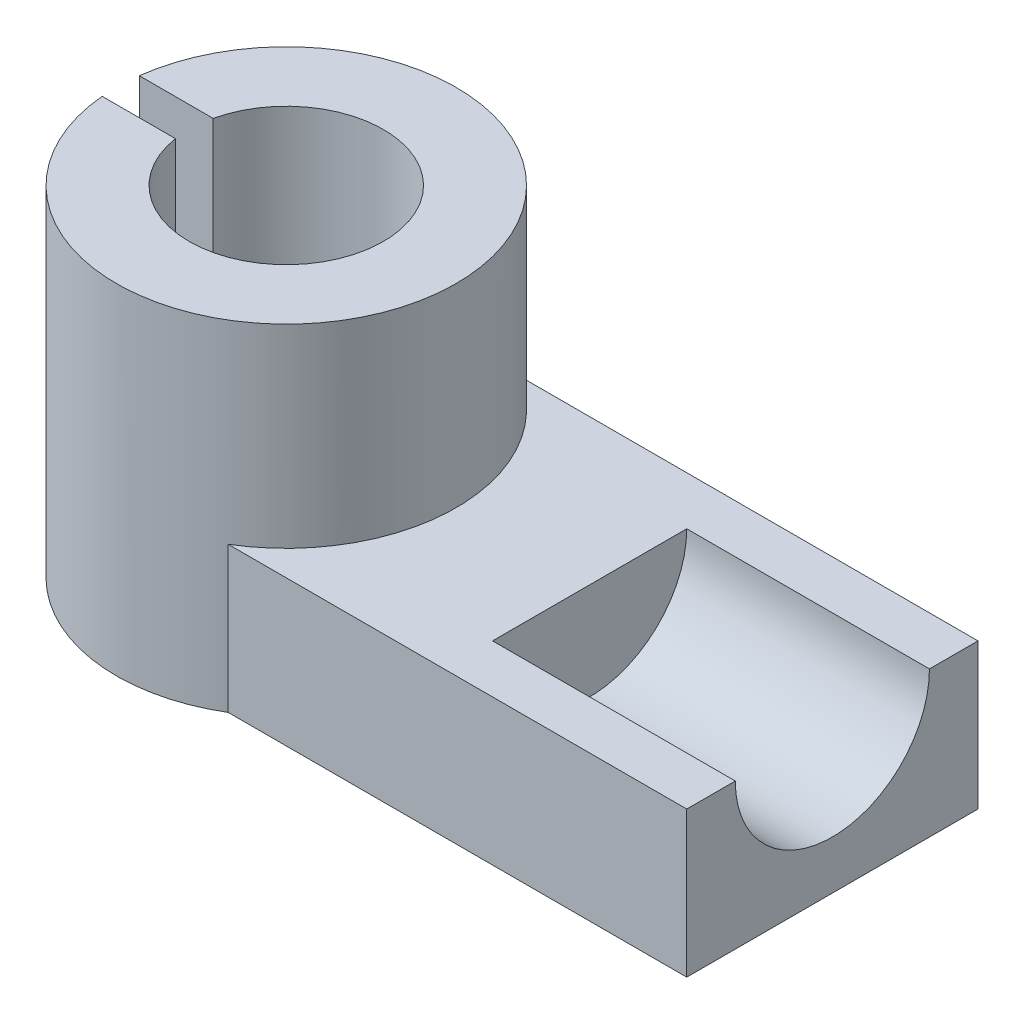
from build123d import *

# Parameters (mm, degrees)
BOSS_EXTRUDE1_DEPTH = 24
SKETCH1_4_R         = 16
BOSS_EXTRUDE2_DEPTH = 56
SKETCH2_W           = 38.610961688
SKETCH2_H           = 6
CUT_EXTRUDE1_DEPTH  = 119.067777145
SKETCH3_R           = 16
CUT_EXTRUDE2_DEPTH  = 40


with BuildPart() as part:
    # Sketch1 → Boss-Extrude1 (new body)
    with BuildSketch(Plane(origin=(0, 0, 0), x_dir=(1, 0, 0), z_dir=(0, 1, 0))):
        with BuildLine():
            ThreePointArc((28, 24), (24.37028665, 10.212718594), (14.422205102, 0))
            Line((14.422205102, 0), (90, 0))
            Line((90, 0), (90, 48))
            Line((90, 48), (14.422205102, 48))
            ThreePointArc((14.422205102, 48), (24.37028665, 37.787281406), (28, 24))
        make_face()
    extrude(amount=BOSS_EXTRUDE1_DEPTH)

    # Sketch1_4 → Boss-Extrude2 (add)
    with BuildSketch(Plane(origin=(0, 0, 0), x_dir=(1, 0, 0), z_dir=(0, 1, 0))):
        with BuildLine():
            ThreePointArc((14.422205102, 48), (-28, 24), (14.422205102, 0))
            ThreePointArc((14.422205102, 0), (24.37028665, 10.212718594), (28, 24))
            ThreePointArc((28, 24), (24.37028665, 37.787281406), (14.422205102, 48))
        make_face()
        with Locations((0, 24)):
            Circle(SKETCH1_4_R, mode=Mode.SUBTRACT)
    extrude(amount=BOSS_EXTRUDE2_DEPTH)

    # Sketch2 → Cut-Extrude1 (cut, through all)
    with BuildSketch(Plane(origin=(0, 56, 0), x_dir=(1, 0, 0), z_dir=(0, 1, 0))):
        with Locations((-21.356464049, 24.552208475)):
            Rectangle(SKETCH2_W, SKETCH2_H)
    extrude(amount=-CUT_EXTRUDE1_DEPTH, mode=Mode.SUBTRACT)

    # Sketch3 → Cut-Extrude2 (cut)
    with BuildSketch(Plane(origin=(90, 0, 0), x_dir=(0, 0, -1), z_dir=(1, 0, 0))):
        with Locations((24, 24)):
            Circle(SKETCH3_R)
    extrude(amount=-CUT_EXTRUDE2_DEPTH, mode=Mode.SUBTRACT)


solid = part.part
